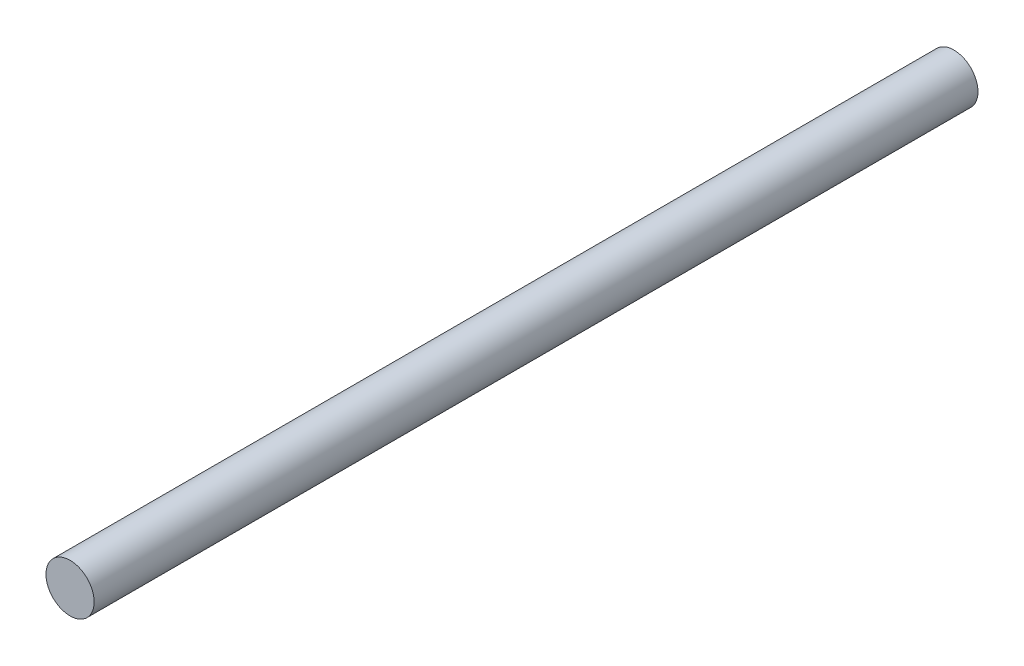
from build123d import *

# Parameters (mm, degrees)
SKETCH_1_R      = 3
EXTRUDE_1_DEPTH = 110


with BuildPart() as part:
    # ｽｹｯﾁ1 → ﾎﾞｽ - 押し出し1 (new body)
    with BuildSketch(Plane.XY):
        Circle(SKETCH_1_R)
    extrude(amount=EXTRUDE_1_DEPTH)


solid = part.part
